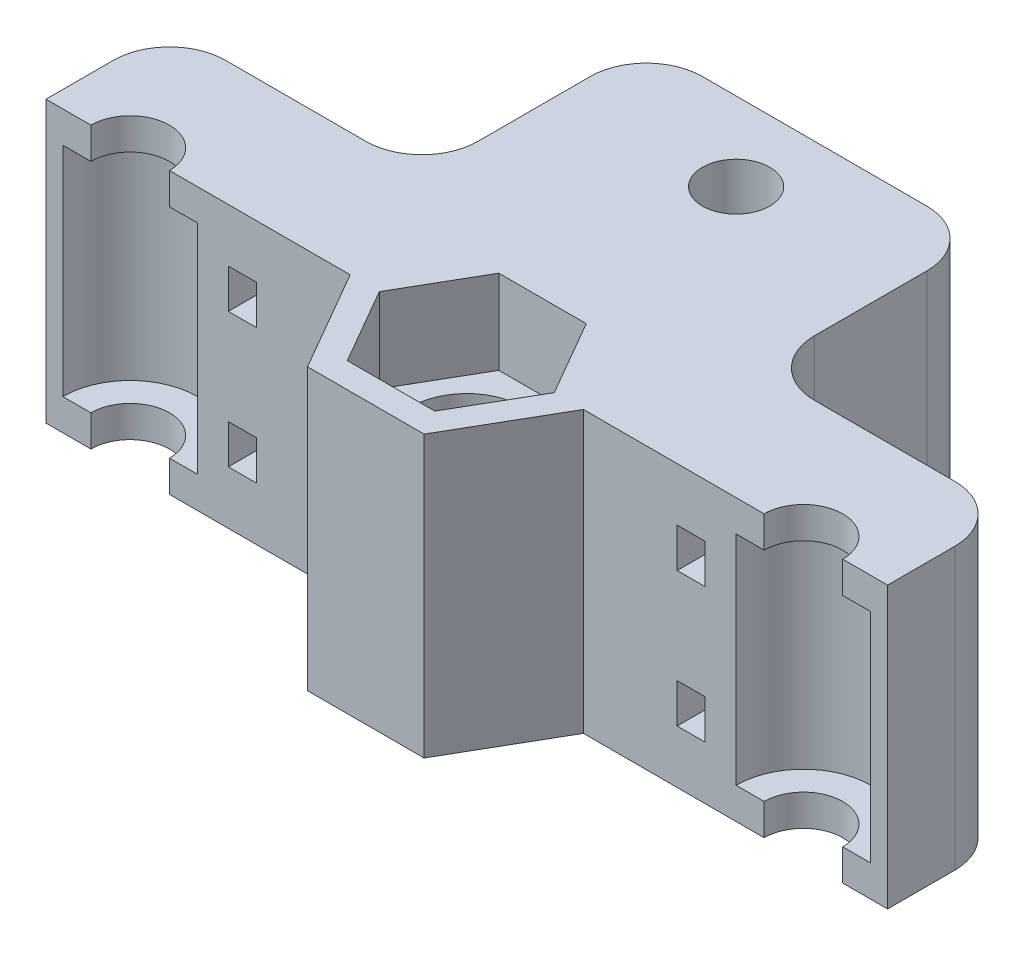
from build123d import *

# Parameters (mm, degrees)
EXTRUDE_1_DEPTH     = 12.5
EXTRUDE_2_DEPTH     = 2.8
SKETCH_3_R          = 5
EXTRUDE_3_DEPTH     = 5
FILLET_1_R          = 5
SKETCH_4_W          = 2.5
SKETCH_4_H          = 3.5
CUT_EXTRUDE_1_DEPTH = 32
SKETCH_5_R          = 3
CUT_EXTRUDE_2_DEPTH = 5


with BuildPart() as part:
    # 草圖1 → 填料-伸長1 (new body, symmetric)
    with BuildSketch(Plane(origin=(0, 0, 0), x_dir=(1, 0, 0), z_dir=(0, 1, 0))):
        with BuildLine():
            Line((-37.5, 5.5), (-15, 5.5))
            Line((-15, 5.5), (-15, 25.5))
            Line((-15, 25.5), (15, 25.5))
            Line((15, 25.5), (15, 5.5))
            Line((15, 5.5), (37.5, 5.5))
            Line((37.5, 5.5), (37.5, -5.5))
            Line((37.5, -5.5), (36, -5.5))
            ThreePointArc((36, -5.5), (30, 0.5), (24, -5.5))
            Line((24, -5.5), (10.392304845, -5.5))
            Line((10.392304845, -5.5), (5.196152423, -14.5))
            Line((5.196152423, -14.5), (-5.196152423, -14.5))
            Line((-5.196152423, -14.5), (-10.392304845, -5.5))
            Line((-10.392304845, -5.5), (-24, -5.5))
            ThreePointArc((-24, -5.5), (-30, 0.5), (-36, -5.5))
            Line((-36, -5.5), (-37.5, -5.5))
            Line((-37.5, -5.5), (-37.5, 5.5))
        make_face()
        Polygon((3.897114317, -12.25), (7.794228634, -5.5), (3.897114317, 1.25), (-3.897114317, 1.25), (-7.794228634, -5.5), (-3.897114317, -12.25), align=None, mode=Mode.SUBTRACT)
    extrude(amount=EXTRUDE_1_DEPTH, both=True)

    # 草圖2 → 填料-伸長2 (add)
    with BuildSketch(Plane(origin=(0, 12.5, 0), x_dir=(1, 0, 0), z_dir=(0, 1, 0))):
        with BuildLine():
            Line((-36, -5.5), (-33.5, -5.5))
            ThreePointArc((-33.5, -5.5), (-30, -2), (-26.5, -5.5))
            Line((-26.5, -5.5), (-24, -5.5))
            ThreePointArc((-24, -5.5), (-30, 0.5), (-36, -5.5))
        make_face()
        with BuildLine():
            Line((26.5, -5.5), (24, -5.5))
            ThreePointArc((24, -5.5), (30, 0.5), (36, -5.5))
            Line((36, -5.5), (33.5, -5.5))
            ThreePointArc((33.5, -5.5), (30, -2), (26.5, -5.5))
        make_face()
    extrude_2 = extrude(amount=-EXTRUDE_2_DEPTH)

    # 鏡射1: 填料-伸長2 across plane
    add(extrude_2.mirror(Plane.ZX))

    # 草圖3 → 填料-伸長3 (add, symmetric)
    with BuildSketch(Plane(origin=(0, 0, 0), x_dir=(1, 0, 0), z_dir=(0, 1, 0))):
        Polygon((7.794228634, -5.5), (3.897114317, 1.25), (-3.897114317, 1.25), (-7.794228634, -5.5), (-3.897114317, -12.25), (3.897114317, -12.25), align=None)
        with Locations((0, -5.5)):
            Circle(SKETCH_3_R, mode=Mode.SUBTRACT)
    extrude(amount=EXTRUDE_3_DEPTH, both=True)

    # 圓角1
    fillet_1_edges = [part.edges().sort_by_distance(p)[0] for p in [
        (-37.5, 0, -5.5),
        (-15, 0, -5.5),
        (-15, 0, -25.5),
        (15, 0, -25.5),
        (15, 0, -5.5),
        (37.5, 0, -5.5),
    ]]
    fillet(fillet_1_edges, radius=FILLET_1_R)

    # 草圖4 → 除料-伸長1 (cut, through all)
    with BuildSketch(Plane.XY.offset(5.5)):
        with Locations((20, 6)):
            Rectangle(SKETCH_4_W, SKETCH_4_H)
        with Locations((20, -6)):
            Rectangle(SKETCH_4_W, SKETCH_4_H)
        with Locations((-20, -6)):
            Rectangle(SKETCH_4_W, SKETCH_4_H)
        with Locations((-20, 6)):
            Rectangle(SKETCH_4_W, SKETCH_4_H)
    extrude(amount=-CUT_EXTRUDE_1_DEPTH, mode=Mode.SUBTRACT)

    # 草圖5 → 除料-伸長2 (cut)
    with BuildSketch(Plane(origin=(0, 12.5, 0), x_dir=(1, 0, 0), z_dir=(0, 1, 0))):
        with Locations((0, 18.5)):
            Circle(SKETCH_5_R)
    extrude(amount=-CUT_EXTRUDE_2_DEPTH, mode=Mode.SUBTRACT)


solid = part.part
